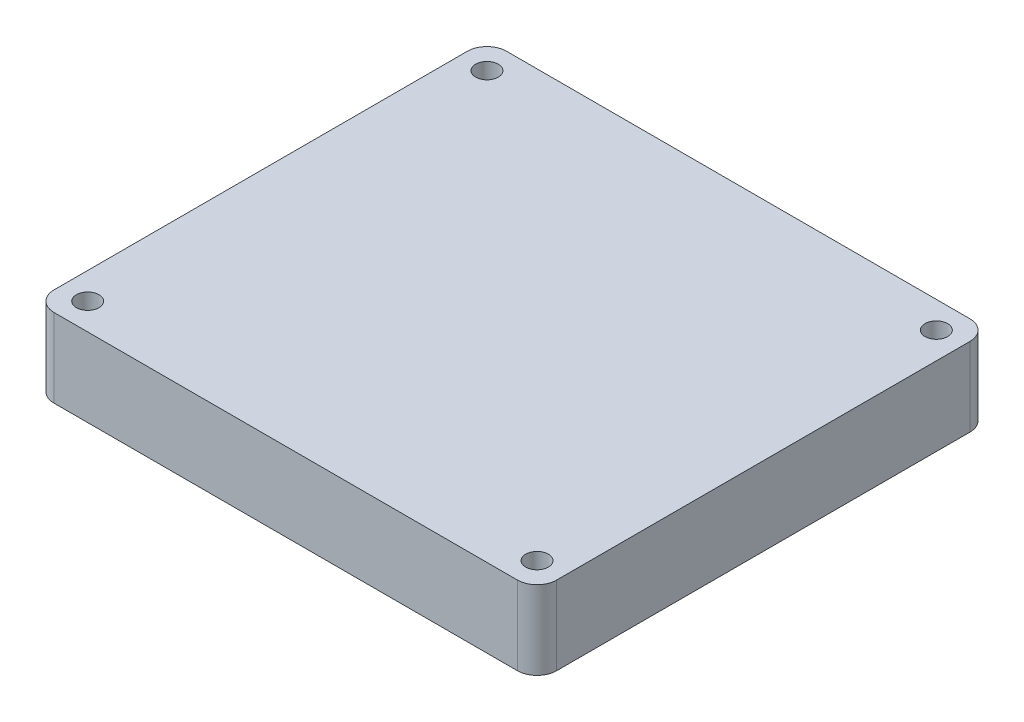
from build123d import *

# Parameters (mm, degrees)
SKETCH1_W           = 64.9986
SKETCH1_H           = 58.5216
BOSS_EXTRUDE1_DEPTH = 10.16
SKETCH2_R           = 1.4605
CUT_EXTRUDE1_DEPTH  = 10.16
FILLET1_R           = 2.54


with BuildPart() as part:
    # Sketch1 → Boss-Extrude1 (new body)
    with BuildSketch(Plane(origin=(0, 0, 0), x_dir=(1, 0, 0), z_dir=(0, 1, 0))):
        with Locations((-33.527176718, 22.375686118)):
            Rectangle(SKETCH1_W, SKETCH1_H)
    extrude(amount=BOSS_EXTRUDE1_DEPTH)

    # Sketch2 → Cut-Extrude1 (cut)
    with BuildSketch(Plane(origin=(0, 10.16, 0), x_dir=(1, 0, 0), z_dir=(0, 1, 0))):
        with Locations((-4.469576718, -3.443413882)):
            Circle(SKETCH2_R)
        with Locations((-4.469576718, 48.194786118)):
            Circle(SKETCH2_R)
        with Locations((-62.584776718, 48.194786118)):
            Circle(SKETCH2_R)
        with Locations((-62.584776718, -3.443413882)):
            Circle(SKETCH2_R)
    extrude(amount=-CUT_EXTRUDE1_DEPTH, mode=Mode.SUBTRACT)

    # Fillet1
    fillet1_edges = [part.edges().sort_by_distance(p)[0] for p in [
        (-66.026476718, 5.08, -51.636486118),
        (-1.027876718, 5.08, -51.636486118),
        (-1.027876718, 5.08, 6.885113882),
        (-66.026476718, 5.08, 6.885113882),
    ]]
    fillet(fillet1_edges, radius=FILLET1_R)


solid = part.part
